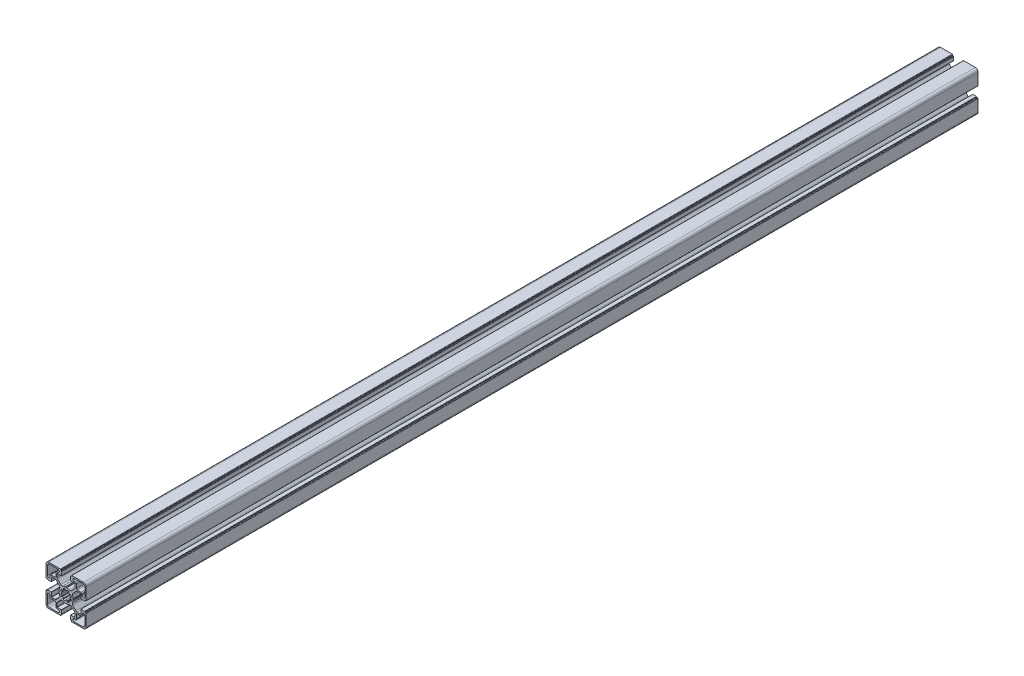
from build123d import *

# Parameters (mm, degrees)
BASE_EXTRUDE_DEPTH = 1000


with BuildPart() as part:
    # Sketch1 → Base-Extrude (new body)
    with BuildSketch(Plane.XY):
        with BuildLine():
            Line((7.973976585, 0.792591518), (7.540060475, 0.046829556))
            ThreePointArc((7.540060475, 0.046829556), (7.534295984, 0.023675638), (7.531329941, 0))
            ThreePointArc((7.531329941, 0), (7.534295984, -0.023675638), (7.540060475, -0.046829556))
            Line((7.540060475, -0.046829556), (7.973976585, -0.792591518))
            ThreePointArc((7.973976585, -0.792591518), (7.996666421, -0.851255641), (8.000014047, -0.914065683))
            ThreePointArc((8.000014047, -0.914065683), (7.719730741, -2.298395946), (7.20036345, -3.611859543))
            ThreePointArc((7.20036345, -3.611859543), (7.018857217, -4.793954471), (7.563483933, -5.85869607))
            Line((7.563483933, -5.85869607), (11.129779889, -9.424988026))
            ThreePointArc((11.129779889, -9.424988026), (11.760624613, -9.84650461), (12.504756513, -9.99452154))
            Line((12.504756513, -9.99452154), (16.316902451, -9.99452154))
            ThreePointArc((16.316902451, -9.99452154), (16.458324055, -9.935942793), (16.516902802, -9.794521189))
            Line((16.516902802, -9.794521189), (16.516902802, -5.200014226))
            ThreePointArc((16.516902802, -5.200014226), (16.575481548, -5.058592621), (16.716903152, -5.000013875))
            Line((16.716903152, -5.000013875), (20.719599904, -5.000013875))
            ThreePointArc((20.719599904, -5.000013875), (20.931731427, -5.087881629), (21.01959918, -5.300013151))
            Line((21.01959918, -5.300013151), (21.01959918, -5.500004099))
            ThreePointArc((21.01959918, -5.500004099), (21.10746708, -5.712135974), (21.319598956, -5.800003874))
            Line((21.319598956, -5.800003874), (21.999979514, -5.800003874))
            ThreePointArc((21.999979514, -5.800003874), (22.35353264, -5.946450374), (22.49997914, -6.300003501))
            Line((22.49997914, -6.300003501), (22.49997914, -19.500016116))
            ThreePointArc((22.49997914, -19.500016116), (21.62130014, -21.621334875), (19.499981381, -22.500013875))
            Line((19.499981381, -22.500013875), (6.375709012, -22.500013875))
            ThreePointArc((6.375709012, -22.500013875), (6.022155886, -22.353567375), (5.875709386, -22.000014249))
            Line((5.875709386, -22.000014249), (5.875709386, -21.30001315))
            ThreePointArc((5.875709386, -21.30001315), (5.787841632, -21.087881628), (5.57571011, -21.000013874))
            Line((5.57571011, -21.000013874), (5.299998776, -21.000013874))
            ThreePointArc((5.299998776, -21.000013874), (5.087867607, -20.912146267), (5, -20.700015099))
            Line((5, -20.700015099), (5, -16.666812433))
            ThreePointArc((5, -16.666812433), (5.058578893, -16.525390475), (5.200000851, -16.466811582))
            Line((5.200000851, -16.466811582), (9.905385218, -16.466811582))
            ThreePointArc((9.905385218, -16.466811582), (10.046806822, -16.408232835), (10.105385569, -16.266811231))
            Line((10.105385569, -16.266811231), (10.105385569, -12.471582956))
            ThreePointArc((10.105385569, -12.471582956), (9.953144588, -11.706215861), (9.519598955, -11.057368968))
            Line((9.519598955, -11.057368968), (5.944897989, -7.482668002))
            ThreePointArc((5.944897989, -7.482668002), (4.854601835, -6.967833724), (3.666499237, -7.173289937))
            ThreePointArc((3.666499237, -7.173289937), (2.309136684, -7.713848333), (0.876396038, -8.000013875))
            ThreePointArc((0.876396038, -8.000013875), (0.81356491, -7.997088573), (0.754749577, -7.974793627))
            Line((0.754749577, -7.974793627), (0.11262846, -7.606936933))
            ThreePointArc((0.11262846, -7.606936933), (0.062963903, -7.559088739), (0, -7.530953975))
            ThreePointArc((0, -7.530953975), (-0.062963903, -7.559088739), (-0.11262846, -7.606936933))
            Line((-0.11262846, -7.606936933), (-0.754749577, -7.974793627))
            ThreePointArc((-0.754749577, -7.974793627), (-0.81356491, -7.997088573), (-0.876396038, -8.000013875))
            ThreePointArc((-0.876396038, -8.000013875), (-2.309136684, -7.713848333), (-3.666499237, -7.173289937))
            ThreePointArc((-3.666499237, -7.173289937), (-4.854601835, -6.967833724), (-5.944897989, -7.482668002))
            Line((-5.944897989, -7.482668002), (-9.519598955, -11.057368968))
            ThreePointArc((-9.519598955, -11.057368968), (-9.953144588, -11.706215861), (-10.105385569, -12.471582956))
            Line((-10.105385569, -12.471582956), (-10.105385569, -16.266811231))
            ThreePointArc((-10.105385569, -16.266811231), (-10.046806822, -16.408232835), (-9.905385218, -16.466811582))
            Line((-9.905385218, -16.466811582), (-5.200000851, -16.466811582))
            ThreePointArc((-5.200000851, -16.466811582), (-5.058578893, -16.525390475), (-5, -16.666812433))
            Line((-5, -16.666812433), (-5, -20.700015099))
            ThreePointArc((-5, -20.700015099), (-5.087867607, -20.912146267), (-5.299998776, -21.000013874))
            Line((-5.299998776, -21.000013874), (-5.57571011, -21.000013874))
            ThreePointArc((-5.57571011, -21.000013874), (-5.787841632, -21.087881628), (-5.875709386, -21.30001315))
            Line((-5.875709386, -21.30001315), (-5.875709386, -22.000014249))
            ThreePointArc((-5.875709386, -22.000014249), (-6.022155886, -22.353567375), (-6.375709012, -22.500013875))
            Line((-6.375709012, -22.500013875), (-19.499981381, -22.500013875))
            ThreePointArc((-19.499981381, -22.500013875), (-21.62130014, -21.621334875), (-22.49997914, -19.500016116))
            Line((-22.49997914, -19.500016116), (-22.49997914, -6.300003501))
            ThreePointArc((-22.49997914, -6.300003501), (-22.35353264, -5.946450374), (-21.999979514, -5.800003874))
            Line((-21.999979514, -5.800003874), (-21.319598956, -5.800003874))
            ThreePointArc((-21.319598956, -5.800003874), (-21.10746708, -5.712135974), (-21.01959918, -5.500004099))
            Line((-21.01959918, -5.500004099), (-21.01959918, -5.300013151))
            ThreePointArc((-21.01959918, -5.300013151), (-20.931731427, -5.087881629), (-20.719599904, -5.000013875))
            Line((-20.719599904, -5.000013875), (-16.716903152, -5.000013875))
            ThreePointArc((-16.716903152, -5.000013875), (-16.575481548, -5.058592621), (-16.516902802, -5.200014226))
            Line((-16.516902802, -5.200014226), (-16.516902802, -9.794521189))
            ThreePointArc((-16.516902802, -9.794521189), (-16.458324055, -9.935942793), (-16.316902451, -9.99452154))
            Line((-16.316902451, -9.99452154), (-12.504756513, -9.99452154))
            ThreePointArc((-12.504756513, -9.99452154), (-11.760624613, -9.84650461), (-11.129779889, -9.424988026))
            Line((-11.129779889, -9.424988026), (-7.563483933, -5.85869607))
            ThreePointArc((-7.563483933, -5.85869607), (-7.018857217, -4.793954471), (-7.20036345, -3.611859543))
            ThreePointArc((-7.20036345, -3.611859543), (-7.719730741, -2.298395946), (-8.000014047, -0.914065683))
            ThreePointArc((-8.000014047, -0.914065683), (-7.996666421, -0.851255641), (-7.973976585, -0.792591518))
            Line((-7.973976585, -0.792591518), (-7.540060475, -0.046829556))
            ThreePointArc((-7.540060475, -0.046829556), (-7.534295984, -0.023675638), (-7.531329941, 0))
            ThreePointArc((-7.531329941, 0), (-7.534295984, 0.023675638), (-7.540060475, 0.046829556))
            Line((-7.540060475, 0.046829556), (-7.973976585, 0.792591518))
            ThreePointArc((-7.973976585, 0.792591518), (-7.996666421, 0.851255641), (-8.000014047, 0.914065683))
            ThreePointArc((-8.000014047, 0.914065683), (-7.719730741, 2.298395946), (-7.20036345, 3.611859543))
            ThreePointArc((-7.20036345, 3.611859543), (-7.018857217, 4.793954471), (-7.563483933, 5.85869607))
            Line((-7.563483933, 5.85869607), (-11.129779889, 9.424988026))
            ThreePointArc((-11.129779889, 9.424988026), (-11.760624613, 9.84650461), (-12.504756513, 9.99452154))
            Line((-12.504756513, 9.99452154), (-16.316902451, 9.99452154))
            ThreePointArc((-16.316902451, 9.99452154), (-16.458324055, 9.935942793), (-16.516902802, 9.794521189))
            Line((-16.516902802, 9.794521189), (-16.516902802, 5.200014226))
            ThreePointArc((-16.516902802, 5.200014226), (-16.575481548, 5.058592621), (-16.716903152, 5.000013875))
            Line((-16.716903152, 5.000013875), (-20.719599904, 5.000013875))
            ThreePointArc((-20.719599904, 5.000013875), (-20.931731427, 5.087881629), (-21.01959918, 5.300013151))
            Line((-21.01959918, 5.300013151), (-21.01959918, 5.500004099))
            ThreePointArc((-21.01959918, 5.500004099), (-21.10746708, 5.712135974), (-21.319598956, 5.800003874))
            Line((-21.319598956, 5.800003874), (-21.999979514, 5.800003874))
            ThreePointArc((-21.999979514, 5.800003874), (-22.35353264, 5.946450374), (-22.49997914, 6.300003501))
            Line((-22.49997914, 6.300003501), (-22.49997914, 19.500016116))
            ThreePointArc((-22.49997914, 19.500016116), (-21.62130014, 21.621334875), (-19.499981381, 22.500013875))
            Line((-19.499981381, 22.500013875), (-6.375709012, 22.500013875))
            ThreePointArc((-6.375709012, 22.500013875), (-6.022155886, 22.353567375), (-5.875709386, 22.000014249))
            Line((-5.875709386, 22.000014249), (-5.875709386, 21.30001315))
            ThreePointArc((-5.875709386, 21.30001315), (-5.787841632, 21.087881628), (-5.57571011, 21.000013874))
            Line((-5.57571011, 21.000013874), (-5.299998776, 21.000013874))
            ThreePointArc((-5.299998776, 21.000013874), (-5.087867607, 20.912146267), (-5, 20.700015099))
            Line((-5, 20.700015099), (-5, 16.666812433))
            ThreePointArc((-5, 16.666812433), (-5.058578893, 16.525390475), (-5.200000851, 16.466811582))
            Line((-5.200000851, 16.466811582), (-9.905385218, 16.466811582))
            ThreePointArc((-9.905385218, 16.466811582), (-10.046806822, 16.408232835), (-10.105385569, 16.266811231))
            Line((-10.105385569, 16.266811231), (-10.105385569, 12.471582956))
            ThreePointArc((-10.105385569, 12.471582956), (-9.953144588, 11.706215861), (-9.519598955, 11.057368968))
            Line((-9.519598955, 11.057368968), (-5.944897989, 7.482668002))
            ThreePointArc((-5.944897989, 7.482668002), (-4.854601835, 6.967833724), (-3.666499237, 7.173289937))
            ThreePointArc((-3.666499237, 7.173289937), (-2.309136684, 7.713848333), (-0.876396038, 8.000013875))
            ThreePointArc((-0.876396038, 8.000013875), (-0.81356491, 7.997088573), (-0.754749577, 7.974793627))
            Line((-0.754749577, 7.974793627), (-0.11262846, 7.606936933))
            ThreePointArc((-0.11262846, 7.606936933), (-0.062963903, 7.559088739), (0, 7.530953975))
            ThreePointArc((0, 7.530953975), (0.062963903, 7.559088739), (0.11262846, 7.606936933))
            Line((0.11262846, 7.606936933), (0.754749577, 7.974793627))
            ThreePointArc((0.754749577, 7.974793627), (0.81356491, 7.997088573), (0.876396038, 8.000013875))
            ThreePointArc((0.876396038, 8.000013875), (2.309136684, 7.713848333), (3.666499237, 7.173289937))
            ThreePointArc((3.666499237, 7.173289937), (4.854601835, 6.967833724), (5.944897989, 7.482668002))
            Line((5.944897989, 7.482668002), (9.519598955, 11.057368968))
            ThreePointArc((9.519598955, 11.057368968), (9.953144588, 11.706215861), (10.105385569, 12.471582956))
            Line((10.105385569, 12.471582956), (10.105385569, 16.266811231))
            ThreePointArc((10.105385569, 16.266811231), (10.046806822, 16.408232835), (9.905385218, 16.466811582))
            Line((9.905385218, 16.466811582), (5.200000851, 16.466811582))
            ThreePointArc((5.200000851, 16.466811582), (5.058578893, 16.525390475), (5, 16.666812433))
            Line((5, 16.666812433), (5, 20.700015099))
            ThreePointArc((5, 20.700015099), (5.087867607, 20.912146267), (5.299998776, 21.000013874))
            Line((5.299998776, 21.000013874), (5.57571011, 21.000013874))
            ThreePointArc((5.57571011, 21.000013874), (5.787841632, 21.087881628), (5.875709386, 21.30001315))
            Line((5.875709386, 21.30001315), (5.875709386, 22.000014249))
            ThreePointArc((5.875709386, 22.000014249), (6.022155886, 22.353567375), (6.375709012, 22.500013875))
            Line((6.375709012, 22.500013875), (19.499981381, 22.500013875))
            ThreePointArc((19.499981381, 22.500013875), (21.62130014, 21.621334875), (22.49997914, 19.500016116))
            Line((22.49997914, 19.500016116), (22.49997914, 6.300003501))
            ThreePointArc((22.49997914, 6.300003501), (22.35353264, 5.946450374), (21.999979514, 5.800003874))
            Line((21.999979514, 5.800003874), (21.319598956, 5.800003874))
            ThreePointArc((21.319598956, 5.800003874), (21.10746708, 5.712135974), (21.01959918, 5.500004099))
            Line((21.01959918, 5.500004099), (21.01959918, 5.300013151))
            ThreePointArc((21.01959918, 5.300013151), (20.931731427, 5.087881629), (20.719599904, 5.000013875))
            Line((20.719599904, 5.000013875), (16.716903152, 5.000013875))
            ThreePointArc((16.716903152, 5.000013875), (16.575481548, 5.058592621), (16.516902802, 5.200014226))
            Line((16.516902802, 5.200014226), (16.516902802, 9.794521189))
            ThreePointArc((16.516902802, 9.794521189), (16.458324055, 9.935942793), (16.316902451, 9.99452154))
            Line((16.316902451, 9.99452154), (12.504756513, 9.99452154))
            ThreePointArc((12.504756513, 9.99452154), (11.760624613, 9.84650461), (11.129779889, 9.424988026))
            Line((11.129779889, 9.424988026), (7.563483933, 5.85869607))
            ThreePointArc((7.563483933, 5.85869607), (7.018857217, 4.793954471), (7.20036345, 3.611859543))
            ThreePointArc((7.20036345, 3.611859543), (7.719730741, 2.298395946), (8.000014047, 0.914065683))
            ThreePointArc((8.000014047, 0.914065683), (7.996666421, 0.851255641), (7.973976585, 0.792591518))
        make_face()
        with BuildLine():
            Line((10.549978885, 18.000013874), (8.999979138, 18.000013874))
            ThreePointArc((8.999979138, 18.000013874), (7.499979138, 19.500013874), (8.999979138, 21.000013874))
            Line((8.999979138, 21.000013874), (18.499981006, 21.000013874))
            ThreePointArc((18.499981006, 21.000013874), (20.267746638, 20.267781374), (20.999979138, 18.500015742))
            Line((20.999979138, 18.500015742), (20.999979138, 9.000204874))
            ThreePointArc((20.999979138, 9.000204874), (19.499979138, 7.500204874), (17.999979138, 9.000204874))
            Line((17.999979138, 9.000204874), (17.999979138, 10.550013621))
            ThreePointArc((17.999979138, 10.550013621), (17.707086138, 11.257119874), (16.999979885, 11.550012874))
            Line((16.999979885, 11.550012874), (12.549977391, 11.550012874))
            ThreePointArc((12.549977391, 11.550012874), (11.842871138, 11.842905874), (11.549978138, 12.550012127))
            Line((11.549978138, 12.550012127), (11.549978138, 17.000014621))
            ThreePointArc((11.549978138, 17.000014621), (11.257085138, 17.707120874), (10.549978885, 18.000013874))
        make_face(mode=Mode.SUBTRACT)
        with BuildLine():
            Line((-0.867388737, 4.924188946), (-0.96752168, 5.481112935))
            ThreePointArc((-0.96752168, 5.481112935), (-1.187855719, 5.829589164), (-1.595071417, 5.894072848))
            ThreePointArc((-1.595071417, 5.894072848), (-2.338895973, 5.643477696), (-3.04438497, 5.299445466))
            ThreePointArc((-3.04438497, 5.299445466), (-3.284615367, 4.964275075), (-3.191311906, 4.562598216))
            Line((-3.191311906, 4.562598216), (-2.864000421, 4.09847552))
            ThreePointArc((-2.864000421, 4.09847552), (-3.53013295, 3.540926624), (-4.08971289, 2.876499344))
            Line((-4.08971289, 2.876499344), (-4.566777651, 3.208162503))
            ThreePointArc((-4.566777651, 3.208162503), (-4.968960845, 3.298770682), (-5.302497889, 3.056460542))
            ThreePointArc((-5.302497889, 3.056460542), (-5.651259984, 2.353310881), (-5.906847665, 1.611199444))
            ThreePointArc((-5.906847665, 1.611199444), (-5.839752063, 1.204293023), (-5.489730697, 0.98621116))
            Line((-5.489730697, 0.98621116), (-4.920545766, 0.887822825))
            ThreePointArc((-4.920545766, 0.887822825), (-4.980096828, 0.445685524), (-5, 0))
            ThreePointArc((-5, 0), (-4.980096828, -0.445685524), (-4.920545766, -0.887822825))
            Line((-4.920545766, -0.887822825), (-5.489730697, -0.98621116))
            ThreePointArc((-5.489730697, -0.98621116), (-5.839752063, -1.204293023), (-5.906847665, -1.611199444))
            ThreePointArc((-5.906847665, -1.611199444), (-5.651259984, -2.353310881), (-5.302497889, -3.056460542))
            ThreePointArc((-5.302497889, -3.056460542), (-4.968960845, -3.298770682), (-4.566777651, -3.208162503))
            Line((-4.566777651, -3.208162503), (-4.08971289, -2.876499344))
            ThreePointArc((-4.08971289, -2.876499344), (-3.53013295, -3.540926624), (-2.864000421, -4.09847552))
            Line((-2.864000421, -4.09847552), (-3.191311906, -4.562598216))
            ThreePointArc((-3.191311906, -4.562598216), (-3.284615367, -4.964275075), (-3.04438497, -5.299445466))
            ThreePointArc((-3.04438497, -5.299445466), (-2.338895973, -5.643477696), (-1.595071417, -5.894072848))
            ThreePointArc((-1.595071417, -5.894072848), (-1.187855719, -5.829589164), (-0.96752168, -5.481112935))
            Line((-0.96752168, -5.481112935), (-0.867388737, -4.924188946))
            ThreePointArc((-0.867388737, -4.924188946), (0, -5), (0.867388737, -4.924188946))
            Line((0.867388737, -4.924188946), (0.96752168, -5.481112935))
            ThreePointArc((0.96752168, -5.481112935), (1.187855719, -5.829589164), (1.595071417, -5.894072848))
            ThreePointArc((1.595071417, -5.894072848), (2.338895973, -5.643477696), (3.04438497, -5.299445466))
            ThreePointArc((3.04438497, -5.299445466), (3.284615367, -4.964275075), (3.191311906, -4.562598216))
            Line((3.191311906, -4.562598216), (2.864000421, -4.09847552))
            ThreePointArc((2.864000421, -4.09847552), (3.53013295, -3.540926624), (4.08971289, -2.876499344))
            Line((4.08971289, -2.876499344), (4.566777651, -3.208162503))
            ThreePointArc((4.566777651, -3.208162503), (4.968960845, -3.298770682), (5.302497889, -3.056460542))
            ThreePointArc((5.302497889, -3.056460542), (5.651259984, -2.353310881), (5.906847665, -1.611199444))
            ThreePointArc((5.906847665, -1.611199444), (5.839752063, -1.204293023), (5.489730697, -0.98621116))
            Line((5.489730697, -0.98621116), (4.920545766, -0.887822825))
            ThreePointArc((4.920545766, -0.887822825), (4.980096828, -0.445685524), (5, 0))
            ThreePointArc((5, 0), (4.980096828, 0.445685524), (4.920545766, 0.887822825))
            Line((4.920545766, 0.887822825), (5.489730697, 0.98621116))
            ThreePointArc((5.489730697, 0.98621116), (5.839752063, 1.204293023), (5.906847665, 1.611199444))
            ThreePointArc((5.906847665, 1.611199444), (5.651259984, 2.353310881), (5.302497889, 3.056460542))
            ThreePointArc((5.302497889, 3.056460542), (4.968960845, 3.298770682), (4.566777651, 3.208162503))
            Line((4.566777651, 3.208162503), (4.08971289, 2.876499344))
            ThreePointArc((4.08971289, 2.876499344), (3.53013295, 3.540926624), (2.864000421, 4.09847552))
            Line((2.864000421, 4.09847552), (3.191311906, 4.562598216))
            ThreePointArc((3.191311906, 4.562598216), (3.284615367, 4.964275075), (3.04438497, 5.299445466))
            ThreePointArc((3.04438497, 5.299445466), (2.338895973, 5.643477696), (1.595071417, 5.894072848))
            ThreePointArc((1.595071417, 5.894072848), (1.187855719, 5.829589164), (0.96752168, 5.481112935))
            Line((0.96752168, 5.481112935), (0.867388737, 4.924188946))
            ThreePointArc((0.867388737, 4.924188946), (0, 5), (-0.867388737, 4.924188946))
        make_face(mode=Mode.SUBTRACT)
        with BuildLine():
            Line((-10.549978885, -18.000013874), (-8.999979138, -18.000013874))
            ThreePointArc((-8.999979138, -18.000013874), (-7.499979138, -19.500013874), (-8.999979138, -21.000013874))
            Line((-8.999979138, -21.000013874), (-18.499981006, -21.000013874))
            ThreePointArc((-18.499981006, -21.000013874), (-20.267746638, -20.267781374), (-20.999979138, -18.500015742))
            Line((-20.999979138, -18.500015742), (-20.999979138, -9.000204874))
            ThreePointArc((-20.999979138, -9.000204874), (-19.499979138, -7.500204874), (-17.999979138, -9.000204874))
            Line((-17.999979138, -9.000204874), (-17.999979138, -10.550013621))
            ThreePointArc((-17.999979138, -10.550013621), (-17.707086138, -11.257119874), (-16.999979885, -11.550012874))
            Line((-16.999979885, -11.550012874), (-12.549977391, -11.550012874))
            ThreePointArc((-12.549977391, -11.550012874), (-11.842871138, -11.842905874), (-11.549978138, -12.550012127))
            Line((-11.549978138, -12.550012127), (-11.549978138, -17.000014621))
            ThreePointArc((-11.549978138, -17.000014621), (-11.257085138, -17.707120874), (-10.549978885, -18.000013874))
        make_face(mode=Mode.SUBTRACT)
        with BuildLine():
            Line((-11.549978138, 12.550012127), (-11.549978138, 17.000014621))
            ThreePointArc((-11.549978138, 17.000014621), (-11.257085138, 17.707120874), (-10.549978885, 18.000013874))
            Line((-10.549978885, 18.000013874), (-8.999979138, 18.000013874))
            ThreePointArc((-8.999979138, 18.000013874), (-7.499979138, 19.500013874), (-8.999979138, 21.000013874))
            Line((-8.999979138, 21.000013874), (-18.499981006, 21.000013874))
            ThreePointArc((-18.499981006, 21.000013874), (-20.267746638, 20.267781374), (-20.999979138, 18.500015742))
            Line((-20.999979138, 18.500015742), (-20.999979138, 9.000204874))
            ThreePointArc((-20.999979138, 9.000204874), (-19.499979138, 7.500204874), (-17.999979138, 9.000204874))
            Line((-17.999979138, 9.000204874), (-17.999979138, 10.550013621))
            ThreePointArc((-17.999979138, 10.550013621), (-17.707086138, 11.257119874), (-16.999979885, 11.550012874))
            Line((-16.999979885, 11.550012874), (-12.549977391, 11.550012874))
            ThreePointArc((-12.549977391, 11.550012874), (-11.842871138, 11.842905874), (-11.549978138, 12.550012127))
        make_face(mode=Mode.SUBTRACT)
        with BuildLine():
            Line((11.549978138, -12.550012127), (11.549978138, -17.000014621))
            ThreePointArc((11.549978138, -17.000014621), (11.257085138, -17.707120874), (10.549978885, -18.000013874))
            Line((10.549978885, -18.000013874), (8.999979138, -18.000013874))
            ThreePointArc((8.999979138, -18.000013874), (7.499979138, -19.500013874), (8.999979138, -21.000013874))
            Line((8.999979138, -21.000013874), (18.499981006, -21.000013874))
            ThreePointArc((18.499981006, -21.000013874), (20.267746638, -20.267781374), (20.999979138, -18.500015742))
            Line((20.999979138, -18.500015742), (20.999979138, -9.000204874))
            ThreePointArc((20.999979138, -9.000204874), (19.499979138, -7.500204874), (17.999979138, -9.000204874))
            Line((17.999979138, -9.000204874), (17.999979138, -10.550013621))
            ThreePointArc((17.999979138, -10.550013621), (17.707086138, -11.257119874), (16.999979885, -11.550012874))
            Line((16.999979885, -11.550012874), (12.549977391, -11.550012874))
            ThreePointArc((12.549977391, -11.550012874), (11.842871138, -11.842905874), (11.549978138, -12.550012127))
        make_face(mode=Mode.SUBTRACT)
    extrude(amount=-BASE_EXTRUDE_DEPTH)


solid = part.part
